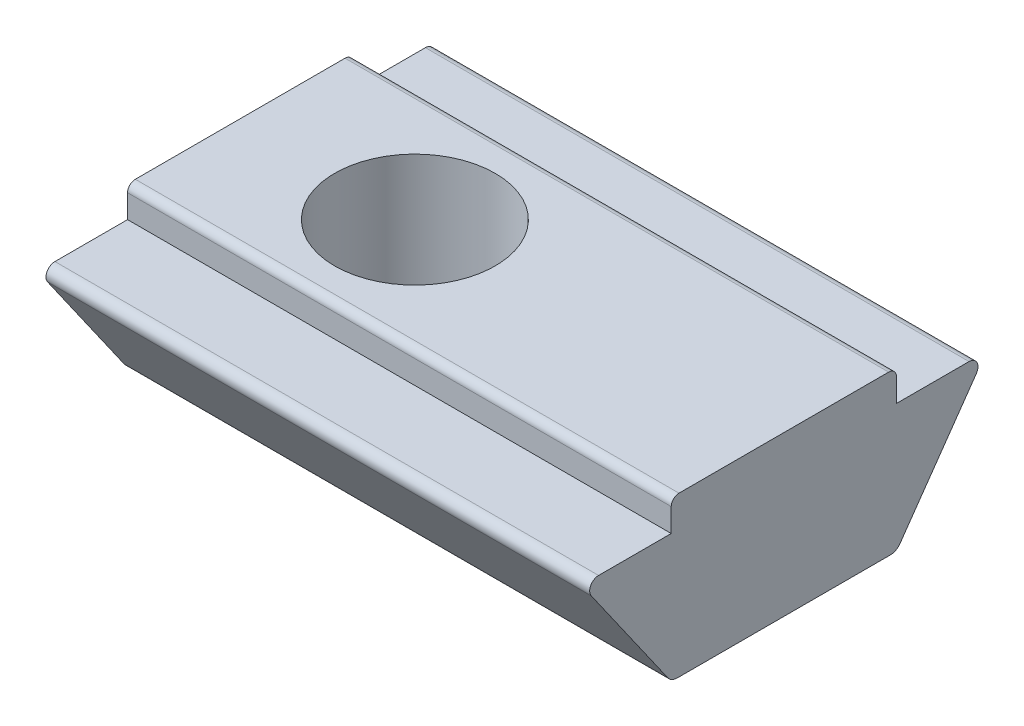
from build123d import *

# Parameters (mm, degrees)
BOSS_EXTRUDE1_DEPTH = 14
FILLET1_R           = 0.3
FILLET2_R           = 0.2
SKETCH2_W           = 2.1
SKETCH2_H           = 0.2
TAPPED_HOLE1_D      = 4.134


with BuildPart() as part:
    # Sketch1 → Boss-Extrude1 (new body)
    with BuildSketch(Plane(origin=(-4.5, 0, 0), x_dir=(0, 0, -1), z_dir=(1, 0, 0))):
        with BuildLine():
            Line((2.9, 0), (-2.9, 0))
            Line((-2.9, 0), (-2.9, -0.8))
            Line((-2.9, -0.8), (-4.77, -0.8))
            ThreePointArc((-4.77, -0.8), (-4.974026325, -0.923824397), (-4.958370592, -1.161971664))
            Line((-4.958370592, -1.161971664), (-2.9, -4.1))
            Line((-2.9, -4.1), (2.9, -4.1))
            Line((2.9, -4.1), (4.958370592, -1.161971664))
            ThreePointArc((4.958370592, -1.161971664), (4.974026325, -0.923824397), (4.77, -0.8))
            Line((4.77, -0.8), (2.9, -0.8))
            Line((2.9, -0.8), (2.9, 0))
        make_face()
    extrude(amount=BOSS_EXTRUDE1_DEPTH)

    # Fillet1
    fillet1_edges = [part.edges().sort_by_distance(p)[0] for p in [
        (2.5, -4.1, -2.9),
        (2.5, -4.1, 2.9),
    ]]
    fillet(fillet1_edges, radius=FILLET1_R)

    # Fillet2
    fillet2_edges = [part.edges().sort_by_distance(p)[0] for p in [
        (2.5, 0, 2.9),
        (2.5, 0, -2.9),
    ]]
    fillet(fillet2_edges, radius=FILLET2_R)

    # Sketch2 → Cut-Revolve1 (revolve, cut)
    with BuildSketch(Plane(origin=(6, 0, 0), x_dir=(0, 0, -1), z_dir=(1, 0, 0))):
        with Locations((1.05, -4)):
            Rectangle(SKETCH2_W, SKETCH2_H)
    revolve(axis=Axis((6, 1.665548573, 0), (0, -1, 0)), mode=Mode.SUBTRACT)

    # Sketch3 → Revolve1 (revolve)
    with BuildSketch(Plane(origin=(6, 0, 0), x_dir=(0, 0, -1), z_dir=(1, 0, 0))):
        with BuildLine():
            Line((1.670329309, -3.9), (0, -3.9))
            Line((0, -3.9), (0, -4.8))
            ThreePointArc((0, -4.8), (0.948683298, -4.560681686), (1.670329309, -3.9))
        make_face()
    revolve(axis=Axis((6, 0, 0), (0, -1, 0)))

    # Tapped Hole1 (through all)
    with Locations(Plane(origin=(0, 0, 0), x_dir=(1, 0, 0), z_dir=(0, 1, 0))):
        with Locations((0, 0)):
            Hole(TAPPED_HOLE1_D / 2)


solid = part.part
